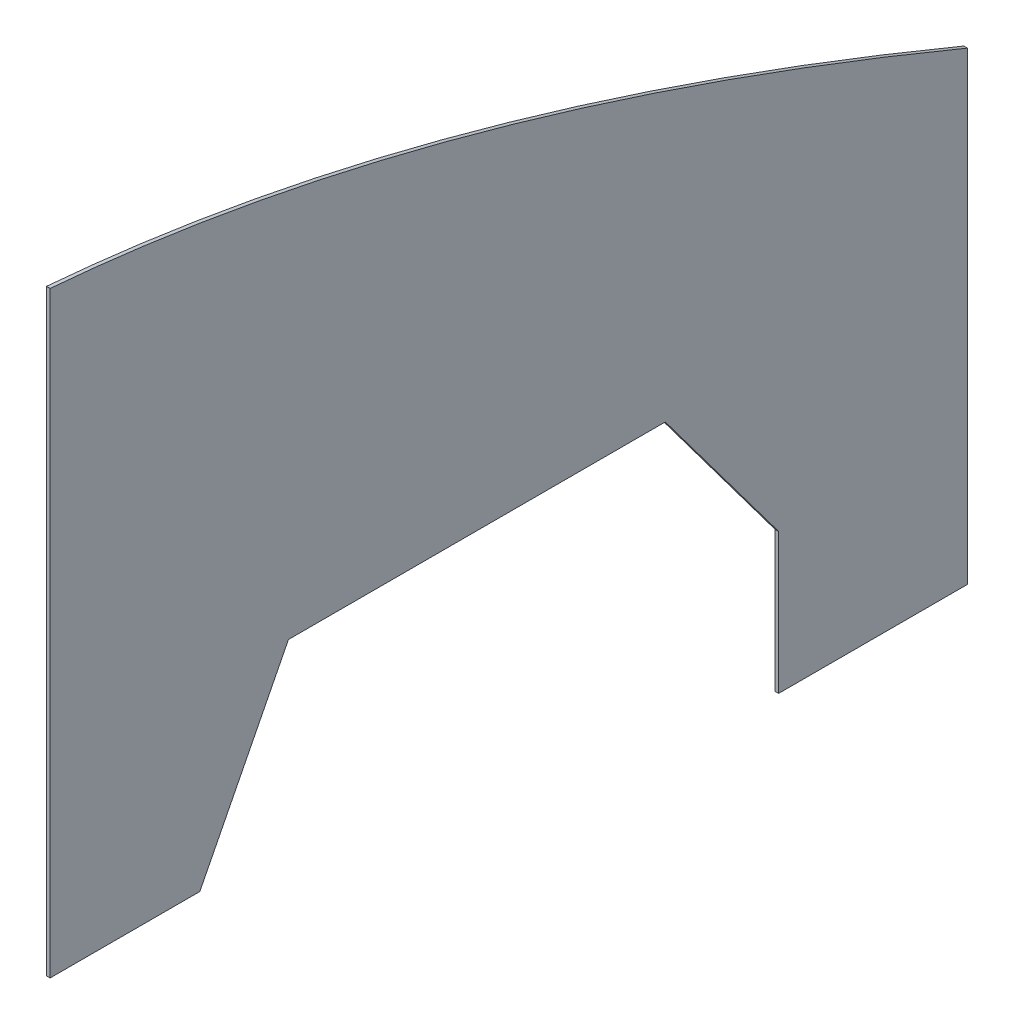
from build123d import *

# Parameters (mm, degrees)
BOSS_EXTRUDE1_DEPTH = 2


with BuildPart() as part:
    # Sketch1 → Boss-Extrude1 (new body)
    with BuildSketch(Plane(origin=(0, 0, 0), x_dir=(0, 0, -1), z_dir=(1, 0, 0))):
        with BuildLine():
            Line((0, 0), (0, 332))
            add(Edge.make_bspline(
                [(0, 332), (217.959962459, 314.031089263), (510, 192.7)],
                knots=[0, 0, 0, 1, 1, 1], degree=2))
            Line((510, 192.7), (510, 0))
            Line((510, 0), (510, -65.5))
            Line((510, -65.5), (405, -65.5))
            Line((405, -65.5), (405, 12.5))
            Line((405, 12.5), (342, 96.7))
            Line((342, 96.7), (132.5, 96.7))
            Line((132.5, 96.7), (83.246188613, 0))
            Line((83.246188613, 0), (0, 0))
        make_face()
    extrude(amount=BOSS_EXTRUDE1_DEPTH)


solid = part.part
